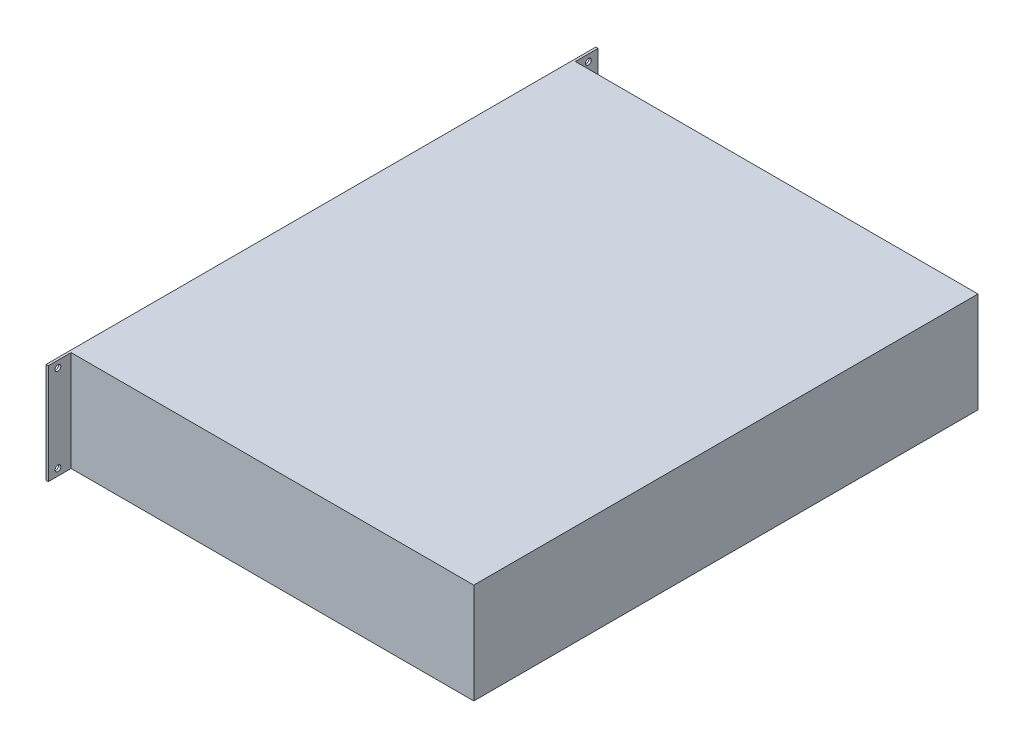
from build123d import *

# Parameters (mm, degrees)
CROQUIS1_W              = 355
CROQUIS1_H              = 442
SALIENTE_EXTRUIR1_DEPTH = 88
CROQUIS2_W              = 482
CROQUIS2_H              = 88
CROQUIS2_R              = 2.5
SALIENTE_EXTRUIR2_DEPTH = 2


with BuildPart() as part:
    # Croquis1 → Saliente-Extruir1 (new body)
    with BuildSketch(Plane(origin=(0, 0, 0), x_dir=(1, 0, 0), z_dir=(0, 1, 0))):
        Rectangle(CROQUIS1_W, CROQUIS1_H)
    extrude(amount=SALIENTE_EXTRUIR1_DEPTH)

    # Croquis2 → Saliente-Extruir2 (add)
    with BuildSketch(Plane.ZY.offset(177.5)):
        with Locations((0, 44)):
            Rectangle(CROQUIS2_W, CROQUIS2_H)
        with Locations((232.5, 82.1)):
            Circle(CROQUIS2_R, mode=Mode.SUBTRACT)
        with Locations((232.5, 5.9)):
            Circle(CROQUIS2_R, mode=Mode.SUBTRACT)
        with Locations((-232.5, 5.9)):
            Circle(CROQUIS2_R, mode=Mode.SUBTRACT)
        with Locations((-232.5, 82.1)):
            Circle(CROQUIS2_R, mode=Mode.SUBTRACT)
    extrude(amount=-SALIENTE_EXTRUIR2_DEPTH)


solid = part.part
